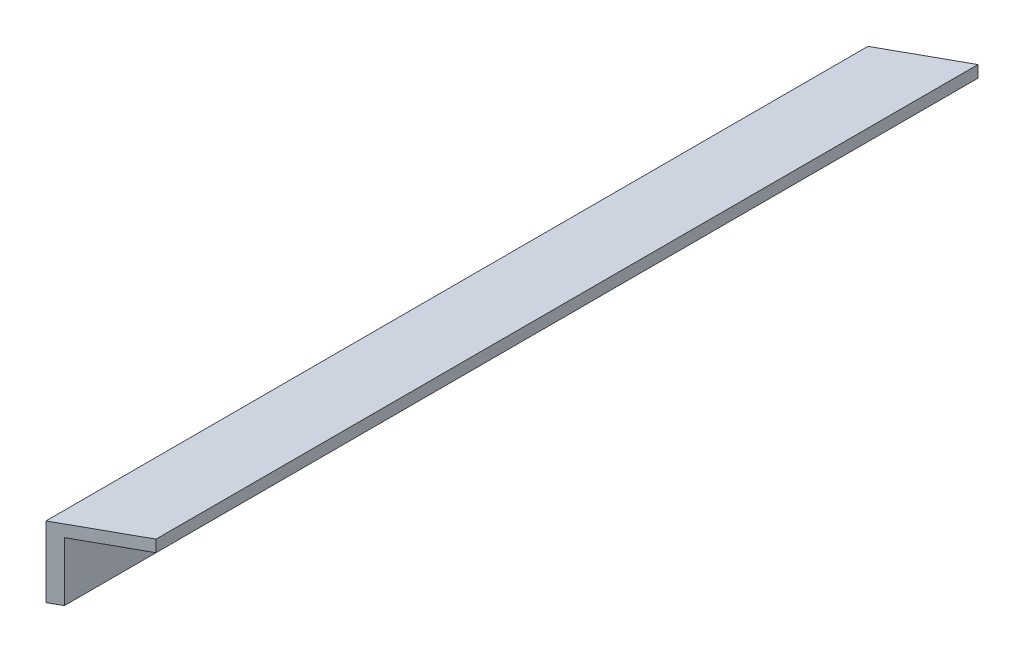
from build123d import *

# Parameters (mm, degrees)
OAL_ANGLE_DEPTH     = 463.55
ANGLE_CUTOURT_DEPTH = 39.1


with BuildPart() as part:
    # Sketch1 → OAL Angle (new body)
    with BuildSketch(Plane.XY):
        Polygon((0, 0), (0, -38.1), (6.35, -38.1), (6.35, -6.35), (38.1, -6.35), (38.1, 0), align=None)
    extrude(amount=OAL_ANGLE_DEPTH)

    # Sketch2 → Angle Cutourt (cut, through all)
    with BuildSketch(Plane(origin=(0, 0, 0), x_dir=(1, 0, 0), z_dir=(0, 1, 0))):
        Polygon((0, 0), (38.1, 0), (0, -21.11917486), align=None)
        Polygon((38.1, -463.55), (0, -463.55), (38.1, -442.43082514), align=None)
    extrude(amount=-ANGLE_CUTOURT_DEPTH, mode=Mode.SUBTRACT)


solid = part.part
